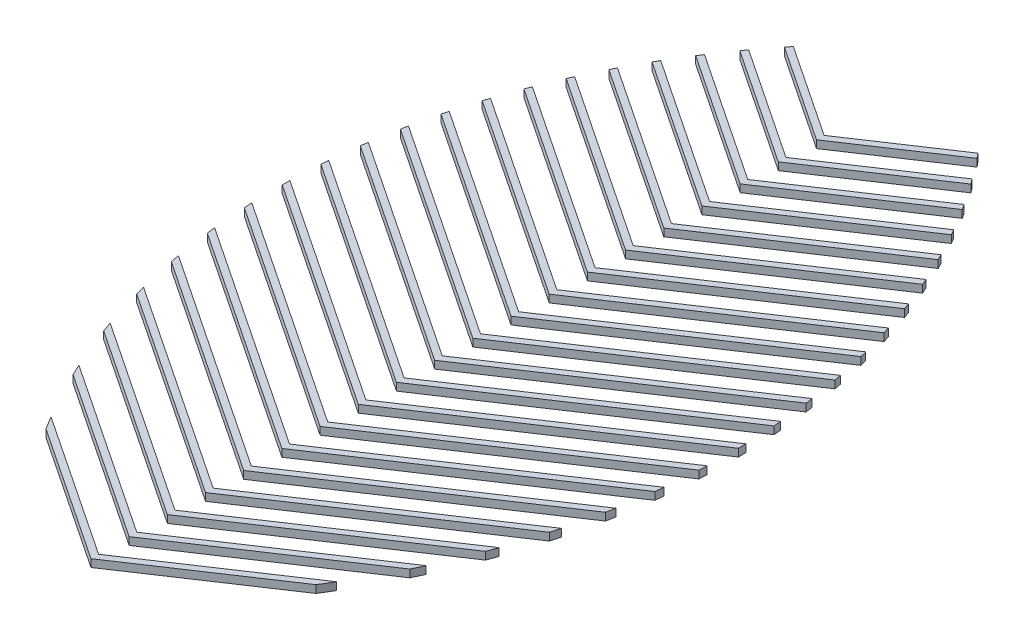
from build123d import *

# Parameters (mm, degrees)
BOSS_EXTRUDE1_DEPTH    = 1.27
BOSS_EXTRUDE1_2_DEPTH  = 1.27
BOSS_EXTRUDE1_3_DEPTH  = 1.27
BOSS_EXTRUDE1_4_DEPTH  = 1.27
BOSS_EXTRUDE1_5_DEPTH  = 1.27
BOSS_EXTRUDE1_6_DEPTH  = 1.27
BOSS_EXTRUDE1_7_DEPTH  = 1.27
BOSS_EXTRUDE1_8_DEPTH  = 1.27
BOSS_EXTRUDE1_9_DEPTH  = 1.27
BOSS_EXTRUDE1_10_DEPTH = 1.27
BOSS_EXTRUDE1_11_DEPTH = 1.27
BOSS_EXTRUDE1_12_DEPTH = 1.27
BOSS_EXTRUDE1_13_DEPTH = 1.27
BOSS_EXTRUDE1_14_DEPTH = 1.27
BOSS_EXTRUDE1_15_DEPTH = 1.27
BOSS_EXTRUDE1_16_DEPTH = 1.27
BOSS_EXTRUDE1_17_DEPTH = 1.27
BOSS_EXTRUDE1_18_DEPTH = 1.27
BOSS_EXTRUDE1_19_DEPTH = 1.27
BOSS_EXTRUDE1_20_DEPTH = 1.27


with BuildPart() as part:
    # Sketch2 → Boss-Extrude1 (new body)
    with BuildSketch(Plane(origin=(0, 0, 0), x_dir=(1, 0, 0), z_dir=(0, 1, 0))):
        with BuildLine():
            Line((-15.087606914, 6.892180812), (8.663604478, -8.941960116))
            Line((8.663604478, -8.941960116), (32.414815871, 6.892180812))
            ThreePointArc((32.414815871, 6.892180812), (31.763310765, 5.814245807), (31.098367122, 4.744548313))
            Line((31.098367122, 4.744548313), (8.663604478, -10.211960116))
            Line((8.663604478, -10.211960116), (-13.771158165, 4.744548313))
            ThreePointArc((-13.771158165, 4.744548313), (-14.436101809, 5.814245807), (-15.087606914, 6.892180812))
        make_face()
    extrude(amount=BOSS_EXTRUDE1_DEPTH)


with BuildPart() as body_2:
    # Sketch2 → Boss-Extrude1 2 (new body)
    with BuildSketch(Plane(origin=(0, 0, 0), x_dir=(1, 0, 0), z_dir=(0, 1, 0))):
        with BuildLine():
            Line((-20.200842721, 16.651004683), (8.663604478, -2.591960116))
            Line((8.663604478, -2.591960116), (37.528051677, 16.651004683))
            ThreePointArc((37.528051677, 16.651004683), (37.100323041, 15.72554455), (36.663241676, 14.804464682))
            Line((36.663241676, 14.804464682), (8.663604478, -3.861960116))
            Line((8.663604478, -3.861960116), (-19.33603272, 14.804464682))
            ThreePointArc((-19.33603272, 14.804464682), (-19.773114085, 15.72554455), (-20.200842721, 16.651004683))
        make_face()
    extrude(amount=BOSS_EXTRUDE1_2_DEPTH)


with BuildPart() as body_3:
    # Sketch2 → Boss-Extrude1 3 (new body)
    with BuildSketch(Plane(origin=(0, 0, 0), x_dir=(1, 0, 0), z_dir=(0, 1, 0))):
        with BuildLine():
            Line((-23.677538133, 25.318801624), (8.663604478, 3.758039884))
            Line((8.663604478, 3.758039884), (41.00474709, 25.318801624))
            ThreePointArc((41.00474709, 25.318801624), (40.709743564, 24.483370348), (40.407397183, 23.650568353))
            Line((40.407397183, 23.650568353), (8.663604478, 2.488039884))
            Line((8.663604478, 2.488039884), (-23.080188226, 23.650568353))
            ThreePointArc((-23.080188226, 23.650568353), (-23.382534608, 24.483370348), (-23.677538133, 25.318801624))
        make_face()
    extrude(amount=BOSS_EXTRUDE1_3_DEPTH)


with BuildPart() as body_4:
    # Sketch2 → Boss-Extrude1 4 (new body)
    with BuildSketch(Plane(origin=(0, 0, 0), x_dir=(1, 0, 0), z_dir=(0, 1, 0))):
        with BuildLine():
            Line((-26.083660644, 33.272883298), (8.663604478, 10.108039884))
            Line((8.663604478, 10.108039884), (43.4108696, 33.272883298))
            ThreePointArc((43.4108696, 33.272883298), (43.208198171, 32.499908642), (42.999395914, 31.728567508))
            Line((42.999395914, 31.728567508), (8.663604478, 8.838039884))
            Line((8.663604478, 8.838039884), (-25.672186958, 31.728567508))
            ThreePointArc((-25.672186958, 31.728567508), (-25.880989214, 32.499908642), (-26.083660644, 33.272883298))
        make_face()
    extrude(amount=BOSS_EXTRUDE1_4_DEPTH)


with BuildPart() as body_5:
    # Sketch2 → Boss-Extrude1 5 (new body)
    with BuildSketch(Plane(origin=(0, 0, 0), x_dir=(1, 0, 0), z_dir=(0, 1, 0))):
        with BuildLine():
            Line((-27.703585423, 40.702833151), (8.663604478, 16.458039884))
            Line((8.663604478, 16.458039884), (45.030794379, 40.702833151))
            ThreePointArc((45.030794379, 40.702833151), (44.898357724, 39.977275913), (44.760607656, 39.252708669))
            Line((44.760607656, 39.252708669), (8.663604478, 15.188039884))
            Line((8.663604478, 15.188039884), (-27.433398699, 39.252708669))
            ThreePointArc((-27.433398699, 39.252708669), (-27.571148767, 39.977275913), (-27.703585423, 40.702833151))
        make_face()
    extrude(amount=BOSS_EXTRUDE1_5_DEPTH)


with BuildPart() as body_6:
    # Sketch2 → Boss-Extrude1 6 (new body)
    with BuildSketch(Plane(origin=(0, 0, 0), x_dir=(1, 0, 0), z_dir=(0, 1, 0))):
        with BuildLine():
            Line((-28.704328317, 47.71999508), (8.663604478, 22.808039884))
            Line((8.663604478, 22.808039884), (46.031537273, 47.71999508))
            ThreePointArc((46.031537273, 47.71999508), (45.955705368, 47.032597992), (45.875151945, 46.345738195))
            Line((45.875151945, 46.345738195), (8.663604478, 21.538039884))
            Line((8.663604478, 21.538039884), (-28.547942988, 46.345738195))
            ThreePointArc((-28.547942988, 46.345738195), (-28.628496412, 47.032597992), (-28.704328317, 47.71999508))
        make_face()
    extrude(amount=BOSS_EXTRUDE1_6_DEPTH)


with BuildPart() as body_7:
    # Sketch2 → Boss-Extrude1 7 (new body)
    with BuildSketch(Plane(origin=(0, 0, 0), x_dir=(1, 0, 0), z_dir=(0, 1, 0))):
        with BuildLine():
            Line((-29.193738592, 54.396268597), (8.663604478, 29.158039884))
            Line((8.663604478, 29.158039884), (46.520947548, 54.396268597))
            ThreePointArc((46.520947548, 54.396268597), (46.492635423, 53.740870856), (46.460052016, 53.085671576))
            Line((46.460052016, 53.085671576), (8.663604478, 27.888039884))
            Line((8.663604478, 27.888039884), (-29.13284306, 53.085671576))
            ThreePointArc((-29.13284306, 53.085671576), (-29.165426466, 53.740870856), (-29.193738592, 54.396268597))
        make_face()
    extrude(amount=BOSS_EXTRUDE1_7_DEPTH)


with BuildPart() as body_8:
    # Sketch2 → Boss-Extrude1 8 (new body)
    with BuildSketch(Plane(origin=(0, 0, 0), x_dir=(1, 0, 0), z_dir=(0, 1, 0))):
        with BuildLine():
            Line((-29.246009729, 60.781116022), (8.663604478, 35.508039884))
            Line((8.663604478, 35.508039884), (46.573218686, 60.781116022))
            ThreePointArc((46.573218686, 60.781116022), (46.586038756, 60.153391226), (46.594942657, 59.52559867))
            Line((46.594942657, 59.52559867), (8.663604478, 34.238039884))
            Line((8.663604478, 34.238039884), (-29.267733701, 59.52559867))
            ThreePointArc((-29.267733701, 59.52559867), (-29.2588298, 60.153391226), (-29.246009729, 60.781116022))
        make_face()
    extrude(amount=BOSS_EXTRUDE1_8_DEPTH)


with BuildPart() as body_9:
    # Sketch2 → Boss-Extrude1 9 (new body)
    with BuildSketch(Plane(origin=(0, 0, 0), x_dir=(1, 0, 0), z_dir=(0, 1, 0))):
        with BuildLine():
            Line((-28.914494067, 66.910105581), (8.663604478, 41.858039884))
            Line((8.663604478, 41.858039884), (46.241703024, 66.910105581))
            ThreePointArc((46.241703024, 66.910105581), (46.290990718, 66.306897384), (46.336650215, 65.703403708))
            Line((46.336650215, 65.703403708), (8.663604478, 40.588039884))
            Line((8.663604478, 40.588039884), (-29.009441259, 65.703403708))
            ThreePointArc((-29.009441259, 65.703403708), (-28.963781762, 66.306897384), (-28.914494067, 66.910105581))
        make_face()
    extrude(amount=BOSS_EXTRUDE1_9_DEPTH)


with BuildPart() as body_10:
    # Sketch2 → Boss-Extrude1 10 (new body)
    with BuildSketch(Plane(origin=(0, 0, 0), x_dir=(1, 0, 0), z_dir=(0, 1, 0))):
        with BuildLine():
            Line((-28.238784609, 72.809632608), (8.663604478, 48.208039884))
            Line((8.663604478, 48.208039884), (45.565993565, 72.809632608))
            ThreePointArc((45.565993565, 72.809632608), (45.648249628, 72.228575035), (45.727116225, 71.647047715))
            Line((45.727116225, 71.647047715), (8.663604478, 46.938039884))
            Line((8.663604478, 46.938039884), (-28.399907268, 71.647047715))
            ThreePointArc((-28.399907268, 71.647047715), (-28.321040671, 72.228575035), (-28.238784609, 72.809632608))
        make_face()
    extrude(amount=BOSS_EXTRUDE1_10_DEPTH)


with BuildPart() as body_11:
    # Sketch2 → Boss-Extrude1 11 (new body)
    with BuildSketch(Plane(origin=(0, 0, 0), x_dir=(1, 0, 0), z_dir=(0, 1, 0))):
        with BuildLine():
            Line((-27.248914654, 78.499719305), (8.663604478, 54.558039884))
            Line((8.663604478, 54.558039884), (44.576123611, 78.499719305))
            ThreePointArc((44.576123611, 78.499719305), (44.688674576, 77.939005878), (44.798037586, 77.377661955))
            Line((44.798037586, 77.377661955), (8.663604478, 53.288039884))
            Line((8.663604478, 53.288039884), (-27.470828629, 77.377661955))
            ThreePointArc((-27.470828629, 77.377661955), (-27.361465619, 77.939005878), (-27.248914654, 78.499719305))
        make_face()
    extrude(amount=BOSS_EXTRUDE1_11_DEPTH)


with BuildPart() as body_12:
    # Sketch2 → Boss-Extrude1 12 (new body)
    with BuildSketch(Plane(origin=(0, 0, 0), x_dir=(1, 0, 0), z_dir=(0, 1, 0))):
        with BuildLine():
            Line((-25.967985314, 83.995766412), (8.663604478, 60.908039884))
            Line((8.663604478, 60.908039884), (43.295194271, 83.995766412))
            ThreePointArc((43.295194271, 83.995766412), (43.435975759, 83.454002944), (43.573741969, 82.911464877))
            Line((43.573741969, 82.911464877), (8.663604478, 59.638039884))
            Line((8.663604478, 59.638039884), (-26.246533012, 82.911464877))
            ThreePointArc((-26.246533012, 82.911464877), (-26.108766803, 83.454002944), (-25.967985314, 83.995766412))
        make_face()
    extrude(amount=BOSS_EXTRUDE1_12_DEPTH)


with BuildPart() as body_13:
    # Sketch2 → Boss-Extrude1 13 (new body)
    with BuildSketch(Plane(origin=(0, 0, 0), x_dir=(1, 0, 0), z_dir=(0, 1, 0))):
        with BuildLine():
            Line((-24.413878016, 89.30969488), (8.663604478, 67.258039884))
            Line((8.663604478, 67.258039884), (41.741086973, 89.30969488))
            ThreePointArc((41.741086973, 89.30969488), (41.908500323, 88.785802168), (42.07304829, 88.261002425))
            Line((42.07304829, 88.261002425), (8.663604478, 65.988039884))
            Line((8.663604478, 65.988039884), (-24.745839334, 88.261002425))
            ThreePointArc((-24.745839334, 88.261002425), (-24.581291366, 88.785802168), (-24.413878016, 89.30969488))
        make_face()
    extrude(amount=BOSS_EXTRUDE1_13_DEPTH)


with BuildPart() as body_14:
    # Sketch2 → Boss-Extrude1 14 (new body)
    with BuildSketch(Plane(origin=(0, 0, 0), x_dir=(1, 0, 0), z_dir=(0, 1, 0))):
        with BuildLine():
            Line((-22.600404845, 94.450712766), (8.663604478, 73.608039884))
            Line((8.663604478, 73.608039884), (39.927613802, 94.450712766))
            ThreePointArc((39.927613802, 94.450712766), (40.120428758, 93.943860588), (40.310509946, 93.435976862))
            Line((40.310509946, 93.435976862), (8.663604478, 72.338039884))
            Line((8.663604478, 72.338039884), (-22.983300989, 93.435976862))
            ThreePointArc((-22.983300989, 93.435976862), (-22.793219802, 93.943860588), (-22.600404845, 94.450712766))
        make_face()
    extrude(amount=BOSS_EXTRUDE1_14_DEPTH)


with BuildPart() as body_15:
    # Sketch2 → Boss-Extrude1 15 (new body)
    with BuildSketch(Plane(origin=(0, 0, 0), x_dir=(1, 0, 0), z_dir=(0, 1, 0))):
        with BuildLine():
            Line((-20.538096709, 99.425840676), (8.663604478, 79.958039884))
            Line((8.663604478, 79.958039884), (37.865305666, 99.425840676))
            ThreePointArc((37.865305666, 99.425840676), (38.082593335, 98.935402349), (38.297263996, 98.443812896))
            Line((38.297263996, 98.443812896), (8.663604478, 78.688039884))
            Line((8.663604478, 78.688039884), (-20.97005504, 98.443812896))
            ThreePointArc((-20.97005504, 98.443812896), (-20.755384379, 98.935402349), (-20.538096709, 99.425840676))
        make_face()
    extrude(amount=BOSS_EXTRUDE1_15_DEPTH)


with BuildPart() as body_16:
    # Sketch2 → Boss-Extrude1 16 (new body)
    with BuildSketch(Plane(origin=(0, 0, 0), x_dir=(1, 0, 0), z_dir=(0, 1, 0))):
        with BuildLine():
            Line((-18.23474744, 104.240274496), (8.663604478, 86.308039884))
            Line((8.663604478, 86.308039884), (35.561956397, 104.240274496))
            ThreePointArc((35.561956397, 104.240274496), (35.80304301, 103.765795549), (36.041617201, 103.290048366))
            Line((36.041617201, 103.290048366), (8.663604478, 85.038039884))
            Line((8.663604478, 85.038039884), (-18.714408244, 103.290048366))
            ThreePointArc((-18.714408244, 103.290048366), (-18.475834053, 103.765795549), (-18.23474744, 104.240274496))
        make_face()
    extrude(amount=BOSS_EXTRUDE1_16_DEPTH)


with BuildPart() as body_17:
    # Sketch2 → Boss-Extrude1 17 (new body)
    with BuildSketch(Plane(origin=(0, 0, 0), x_dir=(1, 0, 0), z_dir=(0, 1, 0))):
        with BuildLine():
            Line((-15.695785688, 108.897633328), (8.663604478, 92.658039884))
            Line((8.663604478, 92.658039884), (33.022994645, 108.897633328))
            ThreePointArc((33.022994645, 108.897633328), (33.287430312, 108.438810337), (33.549448114, 107.978602307))
            Line((33.549448114, 107.978602307), (8.663604478, 91.388039884))
            Line((8.663604478, 91.388039884), (-16.222239157, 107.978602307))
            ThreePointArc((-16.222239157, 107.978602307), (-15.960221355, 108.438810337), (-15.695785688, 108.897633328))
        make_face()
    extrude(amount=BOSS_EXTRUDE1_17_DEPTH)


with BuildPart() as body_18:
    # Sketch2 → Boss-Extrude1 18 (new body)
    with BuildSketch(Plane(origin=(0, 0, 0), x_dir=(1, 0, 0), z_dir=(0, 1, 0))):
        with BuildLine():
            Line((-12.9245188, 113.400122069), (8.663604478, 99.008039884))
            Line((8.663604478, 99.008039884), (30.251727756, 113.400122069))
            ThreePointArc((30.251727756, 113.400122069), (30.539266651, 112.956789246), (30.824473971, 112.511952879))
            Line((30.824473971, 112.511952879), (8.663604478, 97.738039884))
            Line((8.663604478, 97.738039884), (-13.497265014, 112.511952879))
            ThreePointArc((-13.497265014, 112.511952879), (-13.212057694, 112.956789246), (-12.9245188, 113.400122069))
        make_face()
    extrude(amount=BOSS_EXTRUDE1_18_DEPTH)


with BuildPart() as body_19:
    # Sketch2 → Boss-Extrude1 19 (new body)
    with BuildSketch(Plane(origin=(0, 0, 0), x_dir=(1, 0, 0), z_dir=(0, 1, 0))):
        with BuildLine():
            Line((-9.922275394, 117.748626466), (8.663604478, 105.358039884))
            Line((8.663604478, 105.358039884), (27.249484351, 117.748626466))
            ThreePointArc((27.249484351, 117.748626466), (27.560074213, 117.320748546), (27.86841202, 116.891244912))
            Line((27.86841202, 116.891244912), (8.663604478, 104.088039884))
            Line((8.663604478, 104.088039884), (-10.541203064, 116.891244912))
            ThreePointArc((-10.541203064, 116.891244912), (-10.232865256, 117.320748546), (-9.922275394, 117.748626466))
        make_face()
    extrude(amount=BOSS_EXTRUDE1_19_DEPTH)


with BuildPart() as body_20:
    # Sketch2 → Boss-Extrude1 20 (new body)
    with BuildSketch(Plane(origin=(0, 0, 0), x_dir=(1, 0, 0), z_dir=(0, 1, 0))):
        with BuildLine():
            Line((-6.688461368, 121.942750448), (8.663604478, 111.708039884))
            Line((8.663604478, 111.708039884), (24.015670325, 121.942750448))
            ThreePointArc((24.015670325, 121.942750448), (24.349450219, 121.53042118), (24.681052123, 121.116338314))
            Line((24.681052123, 121.116338314), (8.663604478, 110.438039884))
            Line((8.663604478, 110.438039884), (-7.353843166, 121.116338314))
            ThreePointArc((-7.353843166, 121.116338314), (-7.022241262, 121.53042118), (-6.688461368, 121.942750448))
        make_face()
    extrude(amount=BOSS_EXTRUDE1_20_DEPTH)


solid = Compound([part.part, body_2.part, body_3.part, body_4.part, body_5.part, body_6.part, body_7.part, body_8.part, body_9.part, body_10.part, body_11.part, body_12.part, body_13.part, body_14.part, body_15.part, body_16.part, body_17.part, body_18.part, body_19.part, body_20.part])
